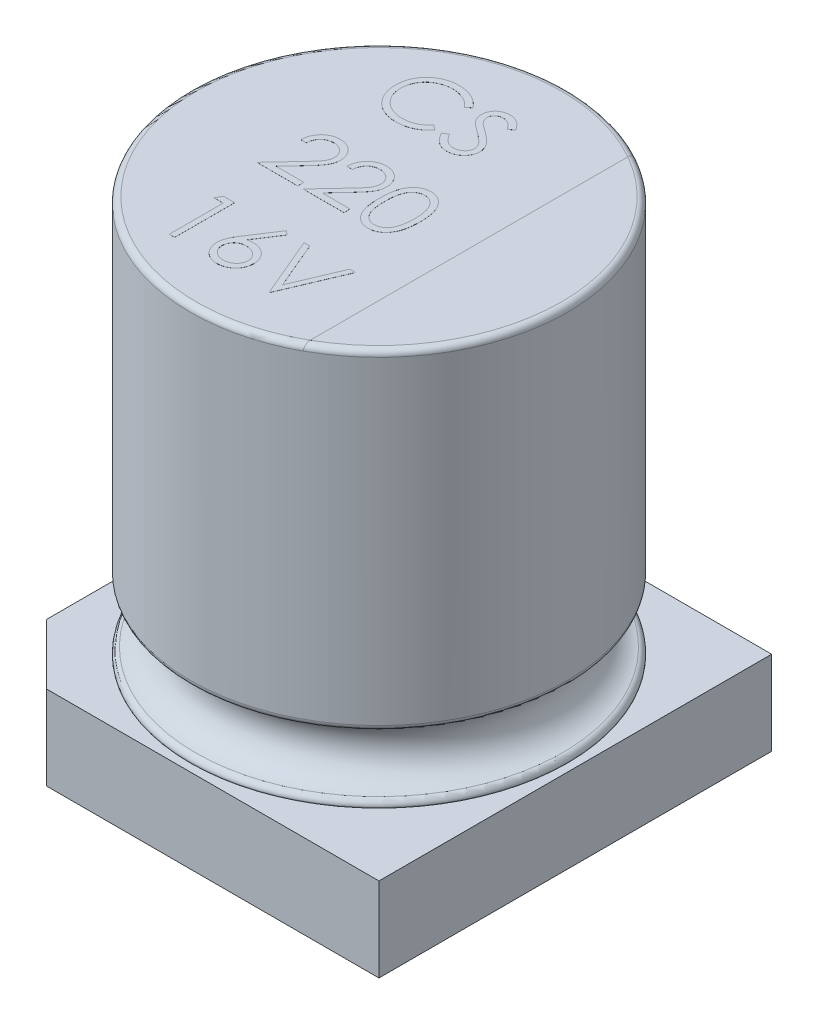
from build123d import *

# Parameters (mm, degrees)
BOSS_EXTRU_1_DEPTH      = 1.4
BOSS_EXTRU_2_DEPTH      = 0.001
BOSS_EXTRU_2_DEPTH_BACK = 1.5
CONG_2_R                = 0.1
BOSS_EXTRU_3_DEPTH      = 0.001


with BuildPart() as part:
    # Esquisse1 → Révolution1 (revolve)
    with BuildSketch(Plane(origin=(0, 0, 0), x_dir=(0, 0, -1), z_dir=(1, 0, 0))):
        with BuildLine():
            Line((-3.14, 7.9), (-3.14, 2.591607978))
            ThreePointArc((-3.14, 2.591607978), (-3.116376262, 2.527058256), (-3.056666667, 2.493006649))
            ThreePointArc((-3.056666667, 2.493006649), (-2.64, 2), (-3.056666667, 1.506993351))
            ThreePointArc((-3.056666667, 1.506993351), (-3.116376262, 1.472941744), (-3.14, 1.408392022))
            Line((-3.14, 1.408392022), (-3.14, 0))
            Line((-3.14, 0), (0, 0))
            Line((0, 0), (0, 8))
            Line((0, 8), (-3.04, 8))
            ThreePointArc((-3.04, 8), (-3.110710678, 7.970710678), (-3.14, 7.9))
        make_face()
    revolve(axis=Axis((0, 8.846825397, 0), (0, -1, 0)))

    # Esquisse2 → Boss.-Extru.1 (add)
    with BuildSketch(Plane.XZ):
        Polygon((-2.27, 3.27), (3.27, 3.27), (3.27, -3.27), (-2.27, -3.27), (-3.27, -2.27), (-3.27, 2.27), align=None)
    extrude(amount=-BOSS_EXTRU_1_DEPTH)

    # Esquisse3 → Boss.-Extru.2 (add, two sides)
    with BuildSketch(Plane(origin=(0, 8, 0), x_dir=(1, 0, 0), z_dir=(0, 1, 0))) as boss_extru_2_sk:
        with BuildLine():
            Line((1.5, 2.758550344), (1.5, -2.758550344))
            ThreePointArc((1.5, -2.758550344), (3.14, 0), (1.5, 2.758550344))
        make_face()
    extrude(amount=BOSS_EXTRU_2_DEPTH)
    extrude(boss_extru_2_sk.sketch, amount=-BOSS_EXTRU_2_DEPTH_BACK)

    # Congé2
    cong_2_edges = [part.edges().sort_by_distance(p)[0] for p in [
        (3.14, 8.001, 0),
    ]]
    fillet(cong_2_edges, radius=CONG_2_R)

    # Esquisse4 → Boss.-Extru.3 (add)
    with BuildSketch(Plane(origin=(0, 8, 0), x_dir=(1, 0, 0), z_dir=(0, 1, 0))):
        with BuildLine():
            Line((-0.49672528, 2.059465238), (-0.575250921, 1.999369084))
            add(Edge.make_bspline(
                [(-0.575250921, 1.999369084), (-0.580852603, 2.006045075), (-0.591980445, 2.019307051), (-0.609883074, 2.037929778), (-0.628540687, 2.055376996), (-0.64794615, 2.071731819), (-0.668448755, 2.086422323), (-0.689551841, 2.100214067), (-0.711608425, 2.112576278), (-0.742108921, 2.127565702), (-0.782008306, 2.143207461), (-0.832235403, 2.15632267), (-0.884667145, 2.164671577), (-0.920437888, 2.165575818), (-0.938632331, 2.166035751)],
                knots=[0, 0, 0, 0, 0.757959112, 1.505699292, 2.245454638, 2.979532153, 3.711538275, 4.438200793, 5.171680507, 5.909471876, 7.393775596, 8.890124382, 10.418191784, 12, 12, 12, 12], degree=3))
            add(Edge.make_bspline(
                [(-0.938632331, 2.166035751), (-0.948656131, 2.165920333), (-0.9686107, 2.165690568), (-0.99822455, 2.16265939), (-1.027285422, 2.158399044), (-1.055774412, 2.152077523), (-1.083655257, 2.144085346), (-1.111110229, 2.134535228), (-1.137741829, 2.122719559), (-1.163918469, 2.109660056), (-1.188998243, 2.094909358), (-1.212728257, 2.078819829), (-1.235021962, 2.061571516), (-1.255896994, 2.043099771), (-1.275374694, 2.023487782), (-1.293313925, 2.002526542), (-1.309652614, 1.980283064), (-1.324714621, 1.957050661), (-1.338203973, 1.932897007), (-1.349498225, 1.907732701), (-1.359499688, 1.881988671), (-1.367413757, 1.855374054), (-1.373677905, 1.828076121), (-1.378000095, 1.80002161), (-1.380996801, 1.77126913), (-1.381225423, 1.751780755), (-1.381340664, 1.741957225)],
                knots=[0, 0, 0, 0, 1.054917814, 2.100044995, 3.131103042, 4.146048494, 5.169673617, 6.183595914, 7.203665975, 8.234915748, 9.262203917, 10.264457458, 11.251630812, 12.227803204, 13.197192746, 14.159520551, 15.12972552, 16.100847026, 17.073214652, 18.039054194, 19.002613845, 19.979014051, 20.95965708, 21.949030935, 22.966165397, 24, 24, 24, 24], degree=3))
            add(Edge.make_bspline(
                [(-1.381340664, 1.741957225), (-1.380980145, 1.727176848), (-1.380272312, 1.698157538), (-1.373972788, 1.655651649), (-1.364399905, 1.614931457), (-1.350052597, 1.576251502), (-1.33236144, 1.539134828), (-1.310006979, 1.504209441), (-1.28411654, 1.470947566), (-1.254323849, 1.440135295), (-1.221636473, 1.411988516), (-1.186565641, 1.387202636), (-1.149198702, 1.366541241), (-1.109948236, 1.349348113), (-1.068512203, 1.336131905), (-1.024965117, 1.32682787), (-0.97940169, 1.320758676), (-0.948267575, 1.320177622), (-0.932422395, 1.319881905)],
                knots=[0, 0, 0, 0, 1.029171465, 2.020641659, 2.987623507, 3.938342917, 4.889210282, 5.84687017, 6.821220943, 7.821438502, 8.827599549, 9.822697543, 10.807740252, 11.797342354, 12.80366471, 13.83203677, 14.896651826, 16, 16, 16, 16], degree=3))
            add(Edge.make_bspline(
                [(-0.932422395, 1.319881905), (-0.914964484, 1.320364413), (-0.880603139, 1.321314105), (-0.830212274, 1.329359605), (-0.781973484, 1.342404724), (-0.735884173, 1.360661274), (-0.692074274, 1.384394213), (-0.650475229, 1.413165035), (-0.611051923, 1.447247416), (-0.587345842, 1.473271167), (-0.575250921, 1.486548571)],
                knots=[0, 0, 0, 0, 1.028121516, 2.023589091, 2.998037872, 3.967518031, 4.937445131, 5.927275754, 6.942489185, 8, 8, 8, 8], degree=3))
            Line((-0.575250921, 1.486548571), (-0.49672528, 1.427053379))
            add(Edge.make_bspline(
                [(-0.49672528, 1.427053379), (-0.50304474, 1.418899535), (-0.51565339, 1.402630905), (-0.536069966, 1.379696131), (-0.557577765, 1.358123549), (-0.58033654, 1.338087086), (-0.60408448, 1.31918581), (-0.629247998, 1.301956716), (-0.655496293, 1.28615932), (-0.68274043, 1.271694485), (-0.710951462, 1.258860985), (-0.740095586, 1.247874195), (-0.770047179, 1.23840994), (-0.80080761, 1.230623673), (-0.832440684, 1.22454622), (-0.864832248, 1.220483456), (-0.898052212, 1.217700052), (-0.920464047, 1.217446362), (-0.931821434, 1.217317802)],
                knots=[0, 0, 0, 0, 0.986787822, 1.968848986, 2.935600012, 3.899624008, 4.868462664, 5.837806735, 6.815139263, 7.798259679, 8.787526145, 9.778297419, 10.776456485, 11.791383307, 12.812564526, 13.85620153, 14.913611965, 16, 16, 16, 16], degree=3))
            add(Edge.make_bspline(
                [(-0.931821434, 1.217317802), (-0.942576767, 1.217392657), (-0.963844107, 1.217540674), (-0.99524375, 1.219938436), (-1.025812202, 1.223209789), (-1.055462095, 1.228135541), (-1.084355231, 1.233948209), (-1.112229684, 1.241739997), (-1.139359744, 1.25046833), (-1.165636413, 1.260726898), (-1.191082041, 1.27230295), (-1.215614559, 1.285386253), (-1.239222682, 1.299866785), (-1.262138517, 1.31542536), (-1.284023541, 1.332561732), (-1.305067405, 1.351037913), (-1.325388112, 1.37079163), (-1.337960308, 1.385035874), (-1.34428137, 1.39219761)],
                knots=[0, 0, 0, 0, 1.114604814, 2.203992996, 3.262667896, 4.300477797, 5.318619304, 6.316056647, 7.298880507, 8.271930387, 9.238335007, 10.195173496, 11.151986948, 12.108099108, 13.064862484, 14.031167946, 15.010108607, 16, 16, 16, 16], degree=3))
            add(Edge.make_bspline(
                [(-1.34428137, 1.39219761), (-1.354405839, 1.404637949), (-1.374532547, 1.429368438), (-1.400282742, 1.469450147), (-1.422324901, 1.511298207), (-1.440146592, 1.555132472), (-1.454078802, 1.600854583), (-1.463730572, 1.648487587), (-1.470002459, 1.697986999), (-1.470719684, 1.731654653), (-1.471084254, 1.748768122)],
                knots=[0, 0, 0, 0, 0.994628077, 1.977248131, 2.950237994, 3.925870899, 4.908910175, 5.911660606, 6.938484602, 8, 8, 8, 8], degree=3))
            add(Edge.make_bspline(
                [(-1.471084254, 1.748768122), (-1.470639913, 1.766755395), (-1.4697657, 1.802144231), (-1.46233833, 1.854079646), (-1.450390102, 1.903837188), (-1.433419563, 1.951323972), (-1.411903748, 1.996789767), (-1.385324716, 2.039887254), (-1.353991246, 2.080892054), (-1.318149084, 2.119181983), (-1.278844131, 2.154193226), (-1.236753042, 2.184994999), (-1.1919582, 2.210628575), (-1.144953099, 2.23205605), (-1.095385761, 2.248525896), (-1.043361942, 2.260055378), (-0.988979395, 2.267231697), (-0.951875844, 2.2681389), (-0.933023357, 2.268599853)],
                knots=[0, 0, 0, 0, 1.032925535, 2.032216505, 3.007276963, 3.968222605, 4.92396291, 5.891752235, 6.871517503, 7.883894988, 8.900124299, 9.891468569, 10.874487609, 11.85992873, 12.854644235, 13.869047385, 14.917252991, 16, 16, 16, 16], degree=3))
            add(Edge.make_bspline(
                [(-0.933023357, 2.268599853), (-0.921533508, 2.268462099), (-0.898790508, 2.26818943), (-0.865146893, 2.265530532), (-0.832391943, 2.261098073), (-0.800503091, 2.25506491), (-0.7693252, 2.247577104), (-0.73909656, 2.237822733), (-0.709639793, 2.226669439), (-0.681140676, 2.213824163), (-0.653735947, 2.199405094), (-0.627434142, 2.183572058), (-0.602444182, 2.166344685), (-0.578590226, 2.147869492), (-0.556271308, 2.127755618), (-0.534853743, 2.106556305), (-0.515064863, 2.083660927), (-0.502849665, 2.067545231), (-0.49672528, 2.059465238)],
                knots=[0, 0, 0, 0, 1.096760587, 2.17092713, 3.219439832, 4.250915756, 5.268269357, 6.278326846, 7.281116186, 8.274029601, 9.260640565, 10.235837813, 11.203064059, 12.156899882, 13.114053108, 14.069676657, 15.032185724, 16, 16, 16, 16], degree=3))
        make_face()
        with BuildLine():
            Line((-0.394161177, 1.435867481), (-0.309625921, 1.486548571))
            add(Edge.make_bspline(
                [(-0.309625921, 1.486548571), (-0.301763567, 1.473387318), (-0.286699601, 1.448170866), (-0.261570642, 1.41409714), (-0.235532667, 1.385136524), (-0.208392857, 1.361457493), (-0.180316872, 1.342814954), (-0.151121428, 1.329614316), (-0.120904911, 1.321381181), (-0.100340962, 1.320381156), (-0.090074639, 1.319881905)],
                knots=[0, 0, 0, 0, 1.272034388, 2.437168799, 3.508375237, 4.49857839, 5.41946034, 6.295179144, 7.148887113, 8, 8, 8, 8], degree=3))
            add(Edge.make_bspline(
                [(-0.090074639, 1.319881905), (-0.081306964, 1.320126097), (-0.063925029, 1.320610208), (-0.038335817, 1.325261866), (-0.013483873, 1.332408188), (0.010118595, 1.34264274), (0.032145913, 1.355025165), (0.051462112, 1.369981216), (0.068161001, 1.386725846), (0.081820748, 1.405406604), (0.092300758, 1.425497218), (0.100355635, 1.446118918), (0.104825656, 1.467595652), (0.105499014, 1.482055785), (0.105838823, 1.489353058)],
                knots=[0, 0, 0, 0, 1.095163259, 2.171163733, 3.241058638, 4.321873601, 5.38011039, 6.391990106, 7.366004449, 8.327778327, 9.272591725, 10.192022065, 11.087607919, 12, 12, 12, 12], degree=3))
            add(Edge.make_bspline(
                [(0.105838823, 1.489353058), (0.105417591, 1.497679015), (0.104561289, 1.514604469), (0.097323723, 1.539575799), (0.085938224, 1.564287962), (0.075434611, 1.579574038), (0.069981451, 1.58751011)],
                knots=[0, 0, 0, 0, 0.938893495, 1.908633276, 2.914225137, 4, 4, 4, 4], degree=3))
            add(Edge.make_bspline(
                [(0.069981451, 1.58751011), (0.065504133, 1.593237774), (0.056104563, 1.605262287), (0.039945274, 1.623160926), (0.020983527, 1.641623332), (-0.000131775, 1.661354491), (-0.0241698, 1.681436718), (-0.050377661, 1.702827655), (-0.079424478, 1.72471382), (-0.099795763, 1.739391696), (-0.110307011, 1.746965238)],
                knots=[0, 0, 0, 0, 0.722233717, 1.516239348, 2.393582979, 3.351407094, 4.387010283, 5.505090956, 6.712668013, 8, 8, 8, 8], degree=3))
            add(Edge.make_bspline(
                [(-0.110307011, 1.746965238), (-0.120828152, 1.75445912), (-0.140943774, 1.768786852), (-0.169074798, 1.790050933), (-0.194230359, 1.809492039), (-0.216298649, 1.827293185), (-0.235269962, 1.843456787), (-0.251293794, 1.857827626), (-0.263961953, 1.870794358), (-0.271006405, 1.87920617), (-0.27416919, 1.882982866)],
                knots=[0, 0, 0, 0, 1.452282411, 2.77665338, 3.964542531, 5.026858415, 5.96415736, 6.766646006, 7.446254459, 8, 8, 8, 8], degree=3))
            add(Edge.make_bspline(
                [(-0.27416919, 1.882982866), (-0.278589917, 1.888868877), (-0.287283871, 1.900444506), (-0.298759872, 1.918537323), (-0.308513919, 1.937058256), (-0.316160299, 1.956057074), (-0.322599219, 1.975267054), (-0.326930056, 1.994938838), (-0.329641884, 2.014984158), (-0.329919594, 2.02847373), (-0.330058613, 2.035226456)],
                knots=[0, 0, 0, 0, 1.068054152, 2.10047183, 3.106115577, 4.101338837, 5.06977816, 6.043150881, 7.020423561, 8, 8, 8, 8], degree=3))
            add(Edge.make_bspline(
                [(-0.330058613, 2.035226456), (-0.329685696, 2.045806391), (-0.328947833, 2.066740124), (-0.322707686, 2.097320361), (-0.312858287, 2.12651648), (-0.299059748, 2.154039433), (-0.281271933, 2.17917257), (-0.260687369, 2.202204995), (-0.236169801, 2.221567447), (-0.209269052, 2.238485178), (-0.179824374, 2.251726871), (-0.14896983, 2.261715723), (-0.116656381, 2.26737551), (-0.094769771, 2.268187729), (-0.083664382, 2.268599853)],
                knots=[0, 0, 0, 0, 1.005424448, 1.989358655, 2.955360095, 3.929531133, 4.905563448, 5.876582895, 6.856512386, 7.866279853, 8.892233794, 9.918561126, 10.94386622, 12, 12, 12, 12], degree=3))
            add(Edge.make_bspline(
                [(-0.083664382, 2.268599853), (-0.071880354, 2.26819341), (-0.048445682, 2.267385124), (-0.013974477, 2.260357258), (0.019214299, 2.248728494), (0.045912374, 2.235531735), (0.066807449, 2.222351331), (0.082742516, 2.210345666), (0.098890359, 2.196524207), (0.115381232, 2.180850137), (0.131935706, 2.163179636), (0.148799549, 2.143633725), (0.166012197, 2.122331852), (0.1770853, 2.107124852), (0.1827619, 2.09932902)],
                knots=[0, 0, 0, 0, 1.286793592, 2.559021753, 3.825965368, 5.121522368, 5.803751409, 6.523245864, 7.299691795, 8.125521123, 9.008227632, 9.944561021, 10.946284179, 12, 12, 12, 12], degree=3))
            Line((0.1827619, 2.09932902), (0.101632092, 2.037830622))
            add(Edge.make_bspline(
                [(0.101632092, 2.037830622), (0.096733254, 2.044141677), (0.087299238, 2.056295292), (0.072976527, 2.073315668), (0.059476914, 2.088863234), (0.046176799, 2.102367556), (0.033778619, 2.114568165), (0.021745178, 2.12501381), (0.010249649, 2.133806837), (-0.004240897, 2.143190712), (-0.022445959, 2.15249257), (-0.045298684, 2.160363735), (-0.069180476, 2.165093753), (-0.085446085, 2.165719149), (-0.093680408, 2.166035751)],
                knots=[0, 0, 0, 0, 1.181633172, 2.275549214, 3.290209073, 4.226197932, 5.078386478, 5.862611352, 6.581680152, 7.217281963, 8.414376989, 9.595101626, 10.782541182, 12, 12, 12, 12], degree=3))
            add(Edge.make_bspline(
                [(-0.093680408, 2.166035751), (-0.104010843, 2.165689551), (-0.123932114, 2.165021937), (-0.152215038, 2.157730512), (-0.177670445, 2.146249981), (-0.199542607, 2.130159987), (-0.217753172, 2.111096846), (-0.23092616, 2.089160031), (-0.238854778, 2.064936487), (-0.239822287, 2.048038871), (-0.240315023, 2.039433187)],
                knots=[0, 0, 0, 0, 1.14458467, 2.207223713, 3.21896685, 4.227309161, 5.202851033, 6.127160689, 7.046193047, 8, 8, 8, 8], degree=3))
            add(Edge.make_bspline(
                [(-0.240315023, 2.039433187), (-0.240202702, 2.034075621), (-0.239977874, 2.02335173), (-0.236842218, 2.007508467), (-0.232813838, 1.991705227), (-0.226430229, 1.97601306), (-0.217617285, 1.960157529), (-0.206044377, 1.943865604), (-0.191469145, 1.926993687), (-0.180304285, 1.916020152), (-0.174409575, 1.910226456)],
                knots=[0, 0, 0, 0, 0.858281714, 1.717966888, 2.583508476, 3.4729293, 4.427298488, 5.488583878, 6.674047936, 8, 8, 8, 8], degree=3))
            add(Edge.make_bspline(
                [(-0.174409575, 1.910226456), (-0.172220611, 1.90827302), (-0.167020135, 1.903632103), (-0.157512727, 1.896034309), (-0.144957642, 1.886662088), (-0.129682728, 1.875065712), (-0.111406339, 1.861613866), (-0.090126465, 1.846478548), (-0.066080313, 1.829168417), (-0.049016909, 1.817066262), (-0.039994511, 1.810667161)],
                knots=[0, 0, 0, 0, 0.420754252, 0.999615792, 1.744751191, 2.668019286, 3.750313428, 4.999500688, 6.413464383, 8, 8, 8, 8], degree=3))
            add(Edge.make_bspline(
                [(-0.039994511, 1.810667161), (-0.029141392, 1.80276963), (-0.008125834, 1.787477155), (0.021776332, 1.764501246), (0.048888849, 1.742030455), (0.073306907, 1.720208282), (0.095271738, 1.699200255), (0.114539658, 1.678753632), (0.131306995, 1.659014897), (0.149358201, 1.633708447), (0.167803292, 1.602628137), (0.183643723, 1.564548641), (0.193631822, 1.52632112), (0.194937969, 1.500627739), (0.195582412, 1.487950815)],
                knots=[0, 0, 0, 0, 1.163667725, 2.253281268, 3.268753668, 4.215851969, 5.092017293, 5.902905408, 6.650798638, 7.335211899, 8.59617414, 9.77448103, 10.901945474, 12, 12, 12, 12], degree=3))
            add(Edge.make_bspline(
                [(0.195582412, 1.487950815), (0.195394659, 1.478985568), (0.195022797, 1.461229172), (0.190748251, 1.435156293), (0.184485489, 1.409833188), (0.175046279, 1.38557287), (0.163525377, 1.361931509), (0.148906449, 1.339529252), (0.131961396, 1.317870281), (0.112523178, 1.29753214), (0.09125292, 1.278861799), (0.068771864, 1.262253495), (0.045043215, 1.248405403), (0.020195696, 1.237105162), (-0.0057764, 1.228267014), (-0.032864339, 1.221863338), (-0.06111277, 1.217933134), (-0.080312908, 1.217525203), (-0.090074639, 1.217317802)],
                knots=[0, 0, 0, 0, 0.983748083, 1.948392443, 2.894712957, 3.844097841, 4.80183111, 5.778335162, 6.776009319, 7.81870978, 8.863265674, 9.881300176, 10.883814829, 11.87499822, 12.874611388, 13.892143829, 14.928324115, 16, 16, 16, 16], degree=3))
            add(Edge.make_bspline(
                [(-0.090074639, 1.217317802), (-0.097627594, 1.217463854), (-0.112638383, 1.217754118), (-0.134841092, 1.220320198), (-0.15659526, 1.223950799), (-0.177627912, 1.229714819), (-0.19821003, 1.236708241), (-0.218252097, 1.245319194), (-0.237763826, 1.255638394), (-0.256854564, 1.267436972), (-0.275475757, 1.281167757), (-0.293452748, 1.297160184), (-0.311375372, 1.314973186), (-0.328714628, 1.335090489), (-0.345821241, 1.357187085), (-0.362357929, 1.381469708), (-0.378666992, 1.407806095), (-0.388899982, 1.426338977), (-0.394161177, 1.435867481)],
                knots=[0, 0, 0, 0, 0.915332311, 1.819136955, 2.706846663, 3.586547465, 4.459518054, 5.340707479, 6.227863349, 7.133153174, 8.059268498, 9.028702269, 10.047606654, 11.120612155, 12.245963614, 13.433783089, 14.680604001, 16, 16, 16, 16], degree=3))
        make_face()
        with BuildLine():
            Line((-1.381340664, 0.168599853), (-1.471084254, 0.168599853))
            add(Edge.make_bspline(
                [(-1.471084254, 0.168599853), (-1.470499353, 0.180505821), (-1.469350624, 0.203888825), (-1.463971112, 0.23798137), (-1.456273719, 0.270568455), (-1.445390446, 0.301388431), (-1.431874367, 0.330713804), (-1.415665788, 0.358428094), (-1.396467545, 0.384425577), (-1.374694192, 0.408465247), (-1.35104601, 0.430518838), (-1.325530027, 0.449563193), (-1.298717162, 0.465653956), (-1.270688762, 0.47910574), (-1.241128601, 0.489202839), (-1.210304927, 0.496694736), (-1.178082317, 0.501202263), (-1.156128025, 0.501686773), (-1.144962459, 0.501933187)],
                knots=[0, 0, 0, 0, 1.10065271, 2.161652631, 3.183658789, 4.190468796, 5.17591951, 6.163126047, 7.15150782, 8.156236427, 9.156009102, 10.134482811, 11.092018607, 12.041330605, 13.001268258, 13.972401359, 14.968799086, 16, 16, 16, 16], degree=3))
            add(Edge.make_bspline(
                [(-1.144962459, 0.501933187), (-1.133997295, 0.501676485), (-1.11245114, 0.501172075), (-1.08100485, 0.496840352), (-1.05106848, 0.490055897), (-1.022700547, 0.480537207), (-0.996127385, 0.467741656), (-0.971149373, 0.452370931), (-0.947469141, 0.434593836), (-0.926152917, 0.413664175), (-0.90657918, 0.391320637), (-0.889692822, 0.36746695), (-0.875231918, 0.342830011), (-0.863178295, 0.317221954), (-0.854305112, 0.29040166), (-0.847568481, 0.262759602), (-0.843760649, 0.234009656), (-0.843176242, 0.21455064), (-0.842879126, 0.204657546)],
                knots=[0, 0, 0, 0, 1.111607364, 2.184268762, 3.212621178, 4.221274766, 5.211760367, 6.196651075, 7.1921475, 8.207485113, 9.220403448, 10.201281604, 11.166441695, 12.114753415, 13.065576456, 14.026450734, 14.996634279, 16, 16, 16, 16], degree=3))
            add(Edge.make_bspline(
                [(-0.842879126, 0.204657546), (-0.843362915, 0.190729593), (-0.844322004, 0.163118103), (-0.852526112, 0.122542428), (-0.865339401, 0.083230023), (-0.880767217, 0.051590794), (-0.896330772, 0.02609551), (-0.910355775, 0.005104451), (-0.926774292, -0.017497111), (-0.945825291, -0.041633493), (-0.967114684, -0.067493752), (-0.990835302, -0.095062265), (-1.017156297, -0.124054199), (-1.035630154, -0.1438558), (-1.045202844, -0.154116493)],
                knots=[0, 0, 0, 0, 1.184426356, 2.348067706, 3.509069118, 4.696110526, 5.333549288, 6.050745305, 6.844228056, 7.710549037, 8.667450064, 9.695053472, 10.805634456, 12, 12, 12, 12], degree=3))
            Line((-1.045202844, -0.154116493), (-1.295403164, -0.421143736))
            Line((-1.295403164, -0.421143736), (-0.830058613, -0.421143736))
            Line((-0.830058613, -0.421143736), (-0.830058613, -0.523707839))
            Line((-0.830058613, -0.523707839), (-1.509545793, -0.523707839))
            Line((-1.509545793, -0.523707839), (-1.12172528, -0.10984566))
            add(Edge.make_bspline(
                [(-1.12172528, -0.10984566), (-1.112283026, -0.099989001), (-1.09414639, -0.081056376), (-1.068494225, -0.05341553), (-1.045454514, -0.027772804), (-1.024878116, -0.004176647), (-1.007211401, 0.017718086), (-0.99153362, 0.037202287), (-0.978972023, 0.05513213), (-0.965339052, 0.075915163), (-0.952135058, 0.101290111), (-0.94078867, 0.132299736), (-0.933870142, 0.164221808), (-0.933040189, 0.185793819), (-0.932622716, 0.196644725)],
                knots=[0, 0, 0, 0, 1.329631726, 2.553950428, 3.673215718, 4.687767853, 5.603093632, 6.413772471, 7.123043292, 7.734684054, 8.834405432, 9.900288307, 10.943827018, 12, 12, 12, 12], degree=3))
            add(Edge.make_bspline(
                [(-0.932622716, 0.196644725), (-0.932804356, 0.203467982), (-0.933162335, 0.21691531), (-0.936321677, 0.236631242), (-0.941096108, 0.25564976), (-0.94793761, 0.274029365), (-0.956968107, 0.291585266), (-0.967960501, 0.308338832), (-0.980643377, 0.324535679), (-0.995315168, 0.339722335), (-1.011432745, 0.353631251), (-1.028459673, 0.365952419), (-1.046473989, 0.376249307), (-1.065399738, 0.384690307), (-1.085184158, 0.391311844), (-1.105865514, 0.39590001), (-1.127386661, 0.398780719), (-1.142081946, 0.399170483), (-1.149569831, 0.399369084)],
                knots=[0, 0, 0, 0, 0.991446411, 1.95395049, 2.89581595, 3.838931463, 4.798493298, 5.75982156, 6.748411868, 7.785213223, 8.824556874, 9.840280684, 10.836137867, 11.835679398, 12.848801643, 13.863922112, 14.911575587, 16, 16, 16, 16], degree=3))
            add(Edge.make_bspline(
                [(-1.149569831, 0.399369084), (-1.157390069, 0.399164789), (-1.172747725, 0.398763588), (-1.19529602, 0.395957112), (-1.216806242, 0.391115443), (-1.2373325, 0.384493536), (-1.256909525, 0.376076808), (-1.275442109, 0.365593453), (-1.292888649, 0.353083883), (-1.309281941, 0.338900867), (-1.324385935, 0.323110124), (-1.337656471, 0.305507277), (-1.349251904, 0.28641373), (-1.359368827, 0.265881001), (-1.367584739, 0.243722778), (-1.373862782, 0.22001772), (-1.378830452, 0.194868754), (-1.38049003, 0.177501587), (-1.381340664, 0.168599853)],
                knots=[0, 0, 0, 0, 1.031018746, 2.02475058, 2.990194455, 3.934040569, 4.864654155, 5.795059489, 6.735614925, 7.690564532, 8.649604399, 9.611025574, 10.590972636, 11.591080095, 12.624614302, 13.701020113, 14.821632451, 16, 16, 16, 16], degree=3))
        make_face()
        with BuildLine():
            Line((-0.612109895, 0.168599853), (-0.701853485, 0.168599853))
            add(Edge.make_bspline(
                [(-0.701853485, 0.168599853), (-0.701268584, 0.180505821), (-0.700119854, 0.203888825), (-0.694740343, 0.23798137), (-0.68704295, 0.270568455), (-0.676159677, 0.301388431), (-0.662643598, 0.330713804), (-0.646435018, 0.358428094), (-0.627236775, 0.384425577), (-0.605463423, 0.408465247), (-0.58181524, 0.430518838), (-0.556299258, 0.449563193), (-0.529486393, 0.465653956), (-0.501457993, 0.47910574), (-0.471897832, 0.489202839), (-0.441074158, 0.496694736), (-0.408851548, 0.501202263), (-0.386897256, 0.501686773), (-0.37573169, 0.501933187)],
                knots=[0, 0, 0, 0, 1.10065271, 2.161652631, 3.183658789, 4.190468796, 5.17591951, 6.163126047, 7.15150782, 8.156236427, 9.156009102, 10.134482811, 11.092018607, 12.041330605, 13.001268258, 13.972401359, 14.968799086, 16, 16, 16, 16], degree=3))
            add(Edge.make_bspline(
                [(-0.37573169, 0.501933187), (-0.364766526, 0.501676485), (-0.34322037, 0.501172075), (-0.311774081, 0.496840352), (-0.281837711, 0.490055897), (-0.253469777, 0.480537207), (-0.226896616, 0.467741656), (-0.201918603, 0.452370931), (-0.178238372, 0.434593836), (-0.156922148, 0.413664175), (-0.137348411, 0.391320637), (-0.120462052, 0.36746695), (-0.106001148, 0.342830011), (-0.093947526, 0.317221954), (-0.085074343, 0.29040166), (-0.078337712, 0.262759602), (-0.07452988, 0.234009656), (-0.073945473, 0.21455064), (-0.073648357, 0.204657546)],
                knots=[0, 0, 0, 0, 1.111607364, 2.184268762, 3.212621178, 4.221274766, 5.211760367, 6.196651075, 7.1921475, 8.207485113, 9.220403448, 10.201281604, 11.166441695, 12.114753415, 13.065576456, 14.026450734, 14.996634279, 16, 16, 16, 16], degree=3))
            add(Edge.make_bspline(
                [(-0.073648357, 0.204657546), (-0.074132146, 0.190729593), (-0.075091235, 0.163118103), (-0.083295343, 0.122542428), (-0.096108632, 0.083230023), (-0.111536448, 0.051590794), (-0.127100003, 0.02609551), (-0.141125005, 0.005104451), (-0.157543523, -0.017497111), (-0.176594522, -0.041633493), (-0.197883914, -0.067493752), (-0.221604532, -0.095062265), (-0.247925527, -0.124054199), (-0.266399385, -0.1438558), (-0.275972075, -0.154116493)],
                knots=[0, 0, 0, 0, 1.184426356, 2.348067706, 3.509069118, 4.696110526, 5.333549288, 6.050745305, 6.844228056, 7.710549037, 8.667450064, 9.695053472, 10.805634456, 12, 12, 12, 12], degree=3))
            Line((-0.275972075, -0.154116493), (-0.526172395, -0.421143736))
            Line((-0.526172395, -0.421143736), (-0.060827844, -0.421143736))
            Line((-0.060827844, -0.421143736), (-0.060827844, -0.523707839))
            Line((-0.060827844, -0.523707839), (-0.740315023, -0.523707839))
            Line((-0.740315023, -0.523707839), (-0.352494511, -0.10984566))
            add(Edge.make_bspline(
                [(-0.352494511, -0.10984566), (-0.343052257, -0.099989001), (-0.324915621, -0.081056376), (-0.299263456, -0.05341553), (-0.276223745, -0.027772804), (-0.255647347, -0.004176647), (-0.237980631, 0.017718086), (-0.222302851, 0.037202287), (-0.209741253, 0.05513213), (-0.196108283, 0.075915163), (-0.182904289, 0.101290111), (-0.171557901, 0.132299736), (-0.164639373, 0.164221808), (-0.16380942, 0.185793819), (-0.163391946, 0.196644725)],
                knots=[0, 0, 0, 0, 1.329631726, 2.553950428, 3.673215718, 4.687767853, 5.603093632, 6.413772471, 7.123043292, 7.734684054, 8.834405432, 9.900288307, 10.943827018, 12, 12, 12, 12], degree=3))
            add(Edge.make_bspline(
                [(-0.163391946, 0.196644725), (-0.163573587, 0.203467982), (-0.163931566, 0.21691531), (-0.167090908, 0.236631242), (-0.171865338, 0.25564976), (-0.178706841, 0.274029365), (-0.187737338, 0.291585266), (-0.198729732, 0.308338832), (-0.211412607, 0.324535679), (-0.226084399, 0.339722335), (-0.242201976, 0.353631251), (-0.259228904, 0.365952419), (-0.27724322, 0.376249307), (-0.296168969, 0.384690307), (-0.315953389, 0.391311844), (-0.336634744, 0.39590001), (-0.358155892, 0.398780719), (-0.372851176, 0.399170483), (-0.380339062, 0.399369084)],
                knots=[0, 0, 0, 0, 0.991446411, 1.95395049, 2.89581595, 3.838931463, 4.798493298, 5.75982156, 6.748411868, 7.785213223, 8.824556874, 9.840280684, 10.836137867, 11.835679398, 12.848801643, 13.863922112, 14.911575587, 16, 16, 16, 16], degree=3))
            add(Edge.make_bspline(
                [(-0.380339062, 0.399369084), (-0.3881593, 0.399164789), (-0.403516956, 0.398763588), (-0.426065251, 0.395957112), (-0.447575473, 0.391115443), (-0.468101731, 0.384493536), (-0.487678756, 0.376076808), (-0.50621134, 0.365593453), (-0.523657879, 0.353083883), (-0.540051172, 0.338900867), (-0.555155166, 0.323110124), (-0.568425702, 0.305507277), (-0.580021134, 0.28641373), (-0.590138058, 0.265881001), (-0.59835397, 0.243722778), (-0.604632013, 0.22001772), (-0.609599683, 0.194868754), (-0.611259261, 0.177501587), (-0.612109895, 0.168599853)],
                knots=[0, 0, 0, 0, 1.031018746, 2.02475058, 2.990194455, 3.934040569, 4.864654155, 5.795059489, 6.735614925, 7.690564532, 8.649604399, 9.611025574, 10.590972636, 11.591080095, 12.624614302, 13.701020113, 14.821632451, 16, 16, 16, 16], degree=3))
        make_face()
        with BuildLine():
            add(Edge.make_bspline(
                [(0.028915746, -0.02410848), (0.029009465, -0.008080655), (0.029191517, 0.023053626), (0.03121678, 0.068420667), (0.034581163, 0.110980749), (0.039191841, 0.150735911), (0.044802693, 0.187696415), (0.052292832, 0.221763489), (0.060810775, 0.253094805), (0.070682903, 0.281792533), (0.081822271, 0.308243305), (0.093946346, 0.33293622), (0.107536287, 0.355833915), (0.121815405, 0.377301855), (0.137361711, 0.396988625), (0.153732794, 0.415172243), (0.171567616, 0.431432457), (0.190259904, 0.446245687), (0.209978894, 0.45923125), (0.230162513, 0.470669175), (0.250949686, 0.480440566), (0.272397167, 0.488123547), (0.294312183, 0.494469504), (0.316771345, 0.498809203), (0.339811735, 0.501539748), (0.355363573, 0.501800796), (0.363250682, 0.501933187)],
                knots=[0, 0, 0, 0, 1.646270934, 3.197905019, 4.663502075, 6.030701355, 7.308322542, 8.50163776, 9.611534131, 10.641858119, 11.616356847, 12.558055219, 13.465016945, 14.349605745, 15.204443733, 16.039544428, 16.859896111, 17.680448484, 18.487036065, 19.28249412, 20.06191084, 20.843045899, 21.620316918, 22.403196591, 23.190181807, 24, 24, 24, 24], degree=3))
            add(Edge.make_bspline(
                [(0.363250682, 0.501933187), (0.371203676, 0.501793811), (0.387019678, 0.501516636), (0.410402642, 0.498852653), (0.433245409, 0.494432332), (0.455450591, 0.488169196), (0.477200587, 0.480399003), (0.498325275, 0.470659827), (0.51895587, 0.459323007), (0.538764524, 0.4460019), (0.557968699, 0.431149821), (0.576096689, 0.414360487), (0.593150142, 0.395803424), (0.609343086, 0.375677177), (0.624216114, 0.353595724), (0.638379952, 0.329943122), (0.651057676, 0.304305732), (0.663267584, 0.277111312), (0.673806723, 0.24760741), (0.683311364, 0.215960335), (0.690991069, 0.181796282), (0.697388004, 0.145294498), (0.702343689, 0.106320931), (0.705953015, 0.064959126), (0.707859611, 0.021181872), (0.708218668, -0.008748942), (0.708402925, -0.02410848)],
                knots=[0, 0, 0, 0, 0.810914788, 1.612654377, 2.396697861, 3.181598691, 3.963628158, 4.749916497, 5.551656086, 6.361998678, 7.18212741, 8.025565596, 8.878627764, 9.750805457, 10.657531673, 11.591944965, 12.560506719, 13.57287815, 14.630710178, 15.753379473, 16.941251878, 18.199788006, 19.531962791, 20.947069417, 22.433333509, 24, 24, 24, 24], degree=3))
            add(Edge.make_bspline(
                [(0.708402925, -0.02410848), (0.708216758, -0.039401025), (0.707854019, -0.069197926), (0.705974389, -0.112778204), (0.702271923, -0.153920502), (0.697640498, -0.192723492), (0.691225937, -0.229025669), (0.683338746, -0.262952654), (0.674581511, -0.29465096), (0.66377157, -0.323860906), (0.651939939, -0.35098997), (0.639067025, -0.376323441), (0.625275647, -0.400085239), (0.610250291, -0.422085166), (0.59423503, -0.442479068), (0.57688709, -0.460906961), (0.558695495, -0.477812867), (0.539434804, -0.492856189), (0.519317218, -0.506023276), (0.498757482, -0.517798662), (0.477390801, -0.527293718), (0.455701386, -0.535446586), (0.433378996, -0.541675287), (0.410451455, -0.545982103), (0.387035388, -0.549002631), (0.371206369, -0.549233054), (0.363250682, -0.549348865)],
                knots=[0, 0, 0, 0, 1.561518951, 3.042555995, 4.452378317, 5.7783523, 7.031515105, 8.214008947, 9.334062868, 10.386615937, 11.391082383, 12.354592575, 13.286541444, 14.194233754, 15.072674879, 15.931287219, 16.775624067, 17.606195743, 18.42308326, 19.229000347, 20.022332153, 20.807536673, 21.593273796, 22.3848459, 23.188221202, 24, 24, 24, 24], degree=3))
            add(Edge.make_bspline(
                [(0.363250682, -0.549348865), (0.355363792, -0.54921562), (0.339812385, -0.548952888), (0.316768835, -0.546234679), (0.294402422, -0.541864536), (0.272602778, -0.535745506), (0.25125806, -0.528255553), (0.230659121, -0.518497357), (0.210576925, -0.507259052), (0.191065052, -0.49446036), (0.172490149, -0.479797022), (0.15474769, -0.463578654), (0.138283399, -0.445400536), (0.122959372, -0.425549701), (0.108395347, -0.404208775), (0.094998383, -0.381086382), (0.08260671, -0.356274208), (0.071279999, -0.329611948), (0.061237523, -0.30071054), (0.05236675, -0.269239346), (0.045362705, -0.234920593), (0.039367575, -0.198029916), (0.034532037, -0.158408793), (0.031230801, -0.116035714), (0.029190425, -0.070937083), (0.029008976, -0.040002862), (0.028915746, -0.02410848)],
                knots=[0, 0, 0, 0, 0.810891512, 1.598919785, 2.382837074, 3.152667961, 3.926044502, 4.706494248, 5.493654104, 6.291793342, 7.103789334, 7.925228297, 8.761435821, 9.622817696, 10.50288917, 11.416980706, 12.369136599, 13.353924996, 14.394355917, 15.514179734, 16.714354668, 17.994756427, 19.357759367, 20.818452758, 22.365282078, 24, 24, 24, 24], degree=3))
        make_face()
        with BuildLine():
            add(Edge.make_bspline(
                [(0.118659336, -0.023707839), (0.118693463, -0.03706461), (0.118759699, -0.06298748), (0.120490042, -0.100656983), (0.122847251, -0.135791363), (0.125887621, -0.16843523), (0.130402749, -0.198478091), (0.135461832, -0.226126572), (0.141618429, -0.251234354), (0.14890272, -0.273973729), (0.157199604, -0.294730605), (0.166258423, -0.314045238), (0.175990058, -0.332145791), (0.186881244, -0.34886968), (0.19874269, -0.364271441), (0.211306479, -0.378623679), (0.225041503, -0.391422816), (0.244042572, -0.406773346), (0.269127279, -0.422635956), (0.300733123, -0.436449124), (0.333209824, -0.445129826), (0.355253038, -0.446233756), (0.366255489, -0.446784762)],
                knots=[0, 0, 0, 0, 1.459021318, 2.831673884, 4.118529203, 5.306027144, 6.411944654, 7.436330062, 8.375795394, 9.233974572, 10.042671642, 10.816086306, 11.563610507, 12.285937304, 12.993564865, 13.685989202, 14.367179055, 15.041617293, 16.353048772, 17.594441528, 18.799311195, 20, 20, 20, 20], degree=3))
            add(Edge.make_bspline(
                [(0.366255489, -0.446784762), (0.37732911, -0.446328253), (0.399453488, -0.445416178), (0.431777429, -0.436616539), (0.463157507, -0.423339528), (0.48774949, -0.40764024), (0.506458788, -0.392689289), (0.519863642, -0.379942247), (0.532167084, -0.365669142), (0.543836249, -0.350269343), (0.554538842, -0.333448633), (0.564271167, -0.315287897), (0.573152123, -0.295736704), (0.578211851, -0.282088207), (0.580798759, -0.275110083)],
                knots=[0, 0, 0, 0, 1.353760809, 2.704726607, 4.075137775, 5.516104923, 6.260822281, 7.007110065, 7.778089737, 8.566572457, 9.372053459, 10.217411131, 11.088608312, 12, 12, 12, 12], degree=3))
            add(Edge.make_bspline(
                [(0.580798759, -0.275110083), (0.583813549, -0.2661873), (0.589934868, -0.248070224), (0.597823946, -0.219966324), (0.604036917, -0.19047982), (0.60962645, -0.159786929), (0.613441609, -0.127661301), (0.616512413, -0.094202334), (0.618321181, -0.059384802), (0.618545395, -0.03572909), (0.618659336, -0.023707839)],
                knots=[0, 0, 0, 0, 0.884706709, 1.796334032, 2.740027952, 3.714592787, 4.726048262, 5.777819803, 6.87074269, 8, 8, 8, 8], degree=3))
            add(Edge.make_bspline(
                [(0.618659336, -0.023707839), (0.618502139, -0.011688533), (0.618194628, 0.0118238), (0.617019203, 0.046257566), (0.613983896, 0.078962641), (0.610612719, 0.110079919), (0.605642084, 0.139437148), (0.600282711, 0.167280092), (0.593082365, 0.193263814), (0.585391, 0.217795123), (0.57658803, 0.24059531), (0.56689782, 0.261770677), (0.556548746, 0.281423456), (0.545308106, 0.299499725), (0.53330934, 0.316080451), (0.520235754, 0.330833193), (0.506605933, 0.344215183), (0.487515309, 0.359490203), (0.462522655, 0.375064973), (0.431423898, 0.389398048), (0.399060857, 0.397628988), (0.377182727, 0.39878947), (0.366255489, 0.399369084)],
                knots=[0, 0, 0, 0, 1.31362396, 2.569729283, 3.763502607, 4.902122613, 5.988968491, 7.01645872, 7.998833611, 8.933434873, 9.825090667, 10.667526885, 11.477055099, 12.250526234, 12.991942729, 13.710640831, 14.402115721, 15.076753259, 16.378508321, 17.609869233, 18.806226677, 20, 20, 20, 20], degree=3))
            add(Edge.make_bspline(
                [(0.366255489, 0.399369084), (0.35519532, 0.398788671), (0.333054833, 0.397626787), (0.300355417, 0.389428714), (0.269011317, 0.375139295), (0.244084753, 0.359438618), (0.224980814, 0.344484814), (0.211528616, 0.331517256), (0.198915423, 0.317332612), (0.187296081, 0.301789208), (0.176413428, 0.285084817), (0.166418853, 0.267088027), (0.157413902, 0.247707637), (0.149104034, 0.226960084), (0.141797524, 0.204222672), (0.135770677, 0.179145816), (0.130202947, 0.151585276), (0.126261442, 0.121379702), (0.122757512, 0.088727658), (0.120505698, 0.053505567), (0.11875391, 0.015772887), (0.118691492, -0.010284015), (0.118659336, -0.023707839)],
                knots=[0, 0, 0, 0, 1.207732386, 2.417664972, 3.655092373, 4.956220595, 5.625982001, 6.301752483, 6.994047911, 7.697131622, 8.419323945, 9.170223765, 9.943494443, 10.752040957, 11.610060368, 12.549350801, 13.567764191, 14.679664412, 15.874934091, 17.154273443, 18.533957287, 20, 20, 20, 20], degree=3))
        make_face(mode=Mode.SUBTRACT)
        Polygon((-1.297005729, -1.290374506), (-1.112109895, -1.290374506), (-1.112109895, -2.290374506), (-1.201853485, -2.290374506), (-1.201853485, -1.392938608), (-1.355699639, -1.392938608), align=None)
        with BuildLine():
            Line((-0.278776562, -1.26473348), (-0.209665985, -1.319020339))
            Line((-0.209665985, -1.319020339), (-0.473888741, -1.723066813))
            add(Edge.make_bspline(
                [(-0.473888741, -1.723066813), (-0.456297234, -1.720262853), (-0.421983009, -1.714793412), (-0.387249895, -1.713891142), (-0.370323036, -1.713451429)],
                knots=[0, 0, 0, 0, 1.025318673, 2, 2, 2, 2], degree=3))
            add(Edge.make_bspline(
                [(-0.370323036, -1.713451429), (-0.360159466, -1.713724604), (-0.34015278, -1.71426234), (-0.310779408, -1.718400583), (-0.282553998, -1.724922044), (-0.255593537, -1.734428402), (-0.229801256, -1.746571932), (-0.205029143, -1.761125895), (-0.181742855, -1.778841804), (-0.159642518, -1.798631791), (-0.139577633, -1.82055093), (-0.121813046, -1.843808454), (-0.106891105, -1.868380135), (-0.09478427, -1.894253525), (-0.085382876, -1.921388742), (-0.078529264, -1.949751068), (-0.074477951, -1.979360059), (-0.073927811, -1.999496681), (-0.073648357, -2.009725467)],
                knots=[0, 0, 0, 0, 1.04369286, 2.054478336, 3.041073146, 4.015093852, 4.984733326, 5.965804835, 6.960378782, 7.985147595, 9.009457201, 10.008161701, 10.986880575, 11.956520048, 12.937015923, 13.931873656, 14.949455224, 16, 16, 16, 16], degree=3))
            add(Edge.make_bspline(
                [(-0.073648357, -2.009725467), (-0.074054958, -2.023719668), (-0.074855053, -2.051256944), (-0.082827567, -2.091364575), (-0.095216037, -2.129573865), (-0.112923902, -2.165274771), (-0.134918868, -2.198418362), (-0.161741038, -2.227785638), (-0.192439177, -2.253977077), (-0.227149691, -2.275878969), (-0.264504824, -2.293765555), (-0.303748251, -2.306612767), (-0.344498865, -2.314522329), (-0.372157324, -2.31551393), (-0.386148357, -2.316015531)],
                knots=[0, 0, 0, 0, 1.031375318, 2.029502543, 3.004789286, 3.987476834, 4.960371455, 5.9300674, 6.912260825, 7.929083631, 8.949397511, 9.960523116, 10.96833055, 12, 12, 12, 12], degree=3))
            add(Edge.make_bspline(
                [(-0.386148357, -2.316015531), (-0.399604557, -2.315578901), (-0.426258933, -2.314714013), (-0.465468303, -2.307009459), (-0.503143451, -2.294521716), (-0.539020417, -2.277317636), (-0.572254878, -2.255586813), (-0.601987917, -2.229426161), (-0.628071281, -2.199394886), (-0.649778316, -2.165497644), (-0.666995096, -2.129071941), (-0.679906503, -2.091089897), (-0.687448287, -2.051689902), (-0.68850216, -2.024981005), (-0.689032972, -2.011528352)],
                knots=[0, 0, 0, 0, 1.012016664, 2.004627821, 2.994792927, 3.992885782, 4.990978636, 5.973936114, 6.964471063, 7.975201453, 8.993600317, 9.990122807, 10.98767138, 12, 12, 12, 12], degree=3))
            add(Edge.make_bspline(
                [(-0.689032972, -2.011528352), (-0.688695416, -2.0012299), (-0.688006192, -1.980202428), (-0.683193795, -1.948355562), (-0.675460996, -1.915769539), (-0.666800926, -1.888125484), (-0.657650752, -1.865479335), (-0.65003574, -1.847221194), (-0.640557456, -1.828432316), (-0.630450775, -1.80846842), (-0.618805956, -1.787844011), (-0.606144342, -1.766214391), (-0.59211587, -1.743923555), (-0.582281538, -1.728796642), (-0.577254126, -1.721063608)],
                knots=[0, 0, 0, 0, 1.173818275, 2.396712641, 3.66331629, 4.989737886, 5.693666774, 6.447286557, 7.243889047, 8.091586357, 8.998013824, 9.943181721, 10.948533338, 12, 12, 12, 12], degree=3))
            Line((-0.577254126, -1.721063608), (-0.278776562, -1.26473348))
        make_face()
        with BuildLine():
            add(Edge.make_bspline(
                [(-0.389153164, -1.816015531), (-0.396770949, -1.81623783), (-0.411650694, -1.816672043), (-0.433481384, -1.819193543), (-0.454142313, -1.823941848), (-0.473907208, -1.829989371), (-0.492406552, -1.838304531), (-0.509774792, -1.848405045), (-0.526079093, -1.86029681), (-0.541148679, -1.873811356), (-0.55481144, -1.888607937), (-0.566577477, -1.904456372), (-0.576726734, -1.920974716), (-0.584978683, -1.938300985), (-0.591404419, -1.956428556), (-0.59605249, -1.975274056), (-0.598639276, -1.994963858), (-0.599069628, -2.008316001), (-0.599289382, -2.015134121)],
                knots=[0, 0, 0, 0, 1.129588631, 2.206414736, 3.251139165, 4.268635594, 5.265702196, 6.250456724, 7.242448911, 8.251968645, 9.246821453, 10.222880186, 11.173611482, 12.116736599, 13.062300278, 14.020270554, 14.989073742, 16, 16, 16, 16], degree=3))
            add(Edge.make_bspline(
                [(-0.599289382, -2.015134121), (-0.599110422, -2.021891258), (-0.598759507, -2.035140998), (-0.59557313, -2.054666478), (-0.590705964, -2.073456452), (-0.583465851, -2.091414052), (-0.574829597, -2.108813), (-0.563428076, -2.125023081), (-0.550794708, -2.141028815), (-0.535693584, -2.155600664), (-0.519486909, -2.1691597), (-0.50217228, -2.181011201), (-0.484126577, -2.191150108), (-0.465106171, -2.199096135), (-0.445380918, -2.20561736), (-0.424786474, -2.210206354), (-0.403308516, -2.21280079), (-0.38875939, -2.213231703), (-0.381340664, -2.213451429)],
                knots=[0, 0, 0, 0, 0.989467248, 1.94019797, 2.891935182, 3.827694429, 4.772920941, 5.730924762, 6.725747692, 7.756678648, 8.79901574, 9.819492441, 10.826891316, 11.826466727, 12.835195252, 13.867842842, 14.912794438, 16, 16, 16, 16], degree=3))
            add(Edge.make_bspline(
                [(-0.381340664, -2.213451429), (-0.373921951, -2.213231686), (-0.359372849, -2.212800739), (-0.337894718, -2.210206548), (-0.317300912, -2.205616649), (-0.297573339, -2.199098714), (-0.278561501, -2.19114054), (-0.260531581, -2.181074277), (-0.243380697, -2.169086815), (-0.227163383, -2.155623836), (-0.212125115, -2.140945878), (-0.199188749, -2.125165957), (-0.188136397, -2.108681987), (-0.1791552, -2.09148259), (-0.171994832, -2.073445594), (-0.167102984, -2.054669387), (-0.163923187, -2.035140237), (-0.163571368, -2.021891001), (-0.163391946, -2.015134121)],
                knots=[0, 0, 0, 0, 1.087397944, 2.132534446, 3.165364764, 4.174271784, 5.174024072, 6.181601208, 7.194203697, 8.236725232, 9.267838612, 10.269026844, 11.221737037, 12.171628256, 13.107553087, 14.05945871, 15.010357665, 16, 16, 16, 16], degree=3))
            add(Edge.make_bspline(
                [(-0.163391946, -2.015134121), (-0.163549173, -2.008307107), (-0.163857758, -1.994907897), (-0.167348029, -1.975282863), (-0.172188707, -1.956332805), (-0.179498144, -1.938176819), (-0.1889943, -1.920886554), (-0.200560988, -1.904374668), (-0.213941722, -1.888514569), (-0.229398162, -1.873782338), (-0.246223943, -1.860311744), (-0.26411411, -1.848420443), (-0.282830674, -1.838384735), (-0.302354658, -1.830011277), (-0.322909767, -1.82396857), (-0.34416415, -1.819210501), (-0.366389648, -1.816678496), (-0.381468679, -1.816239334), (-0.389153164, -1.816015531)],
                knots=[0, 0, 0, 0, 0.978206639, 1.919901502, 2.851605144, 3.780102724, 4.718870031, 5.675451981, 6.667674623, 7.690630536, 8.733308323, 9.756129687, 10.767539656, 11.776269907, 12.797430371, 13.836405707, 14.897401972, 16, 16, 16, 16], degree=3))
        make_face(mode=Mode.SUBTRACT)
        Polygon((0.041736259, -1.290374506), (0.137890105, -1.290374506), (0.471223438, -2.078435403), (0.804556771, -1.290374506), (0.900710618, -1.290374506), (0.477633695, -2.290374506), (0.464813182, -2.290374506), align=None)
    extrude(amount=BOSS_EXTRU_3_DEPTH)


solid = part.part
